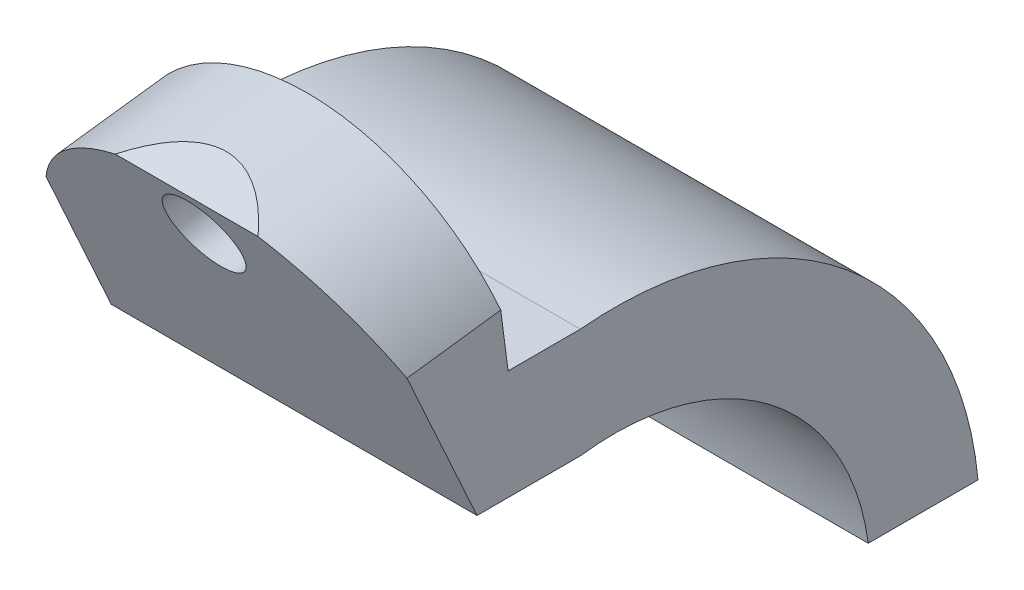
from build123d import *

# Parameters (mm, degrees)
BOSS_EXTRUDE1_DEPTH  = 100
BOSS_EXTRUDE15_DEPTH = 100
SKETCH12_R           = 10.538298665
CUT_EXTRUDE1_DEPTH   = 100
CUT_EXTRUDE4_DEPTH   = 100


with BuildPart() as part:
    # Sketch1 → Boss-Extrude1 (new body)
    with BuildSketch(Plane(origin=(0, 0, 0), x_dir=(0, 0, -1), z_dir=(1, 0, 0))):
        with BuildLine():
            Line((0, -20.471600717), (30, -20.471600717))
            ThreePointArc((30, -20.471600717), (-5.700994218, 47.06632084), (-78.701931645, 69.578428053))
            Line((-78.701931645, 69.578428053), (-78.701931645, 39.578428053))
            ThreePointArc((-78.701931645, 39.578428053), (-26.914197654, 25.853117404), (0, -20.471600717))
        make_face()
    extrude(amount=BOSS_EXTRUDE1_DEPTH)

    # 3DSketch6 → Boss-Extrude15 (add)
    with BuildSketch(Plane(origin=(100, 39.578428053, 78.701931645), x_dir=(0, 0.7502508437816612, 0.661153288886099), z_dir=(-1, 0, 0))):
        Polygon((0, 0), (10.699765669, -12.141674792), (18.673279749, -21.189706114), (31.636766263, -17.247671387), (88.356194396, 0), (78.117236691, 33.671085949), (35.570814657, 5.010889827), (22.507525313, 19.834598667), align=None)
    extrude(amount=BOSS_EXTRUDE15_DEPTH)

    # Sketch12 → Cut-Extrude1 (cut)
    with BuildSketch(Plane(origin=(0, -11.452264846, 87.90339576), x_dir=(-1, 0, 0), z_dir=(0, 0.12919059900394475, -0.9916197805252788))):
        with Locations(Location((-50, 109.830380232, 0), (0, 0, 90))):
            Circle(SKETCH12_R)
    extrude(amount=-CUT_EXTRUDE1_DEPTH, mode=Mode.SUBTRACT)

    # Sketch13 → Cut-Extrude4 (cut)
    with BuildSketch(Plane(origin=(0, -11.452264846, 87.90339576), x_dir=(-1, 0, 0), z_dir=(0, 0.12919059900394475, -0.9916197805252788))):
        with BuildLine():
            Line((-100, 97.256951485), (-100, 133.014656874))
            Line((-100, 133.014656874), (-100, 156.830890058))
            Line((-100, 156.830890058), (0, 160.198008755))
            Line((0, 160.198008755), (0, 133.014656874))
            Line((0, 133.014656874), (0, 94.208847546))
            ThreePointArc((0, 94.208847546), (-49.07241929, 126.164299771), (-100, 97.256951485))
        make_face()
    extrude(amount=-CUT_EXTRUDE4_DEPTH, mode=Mode.SUBTRACT)


solid = part.part
